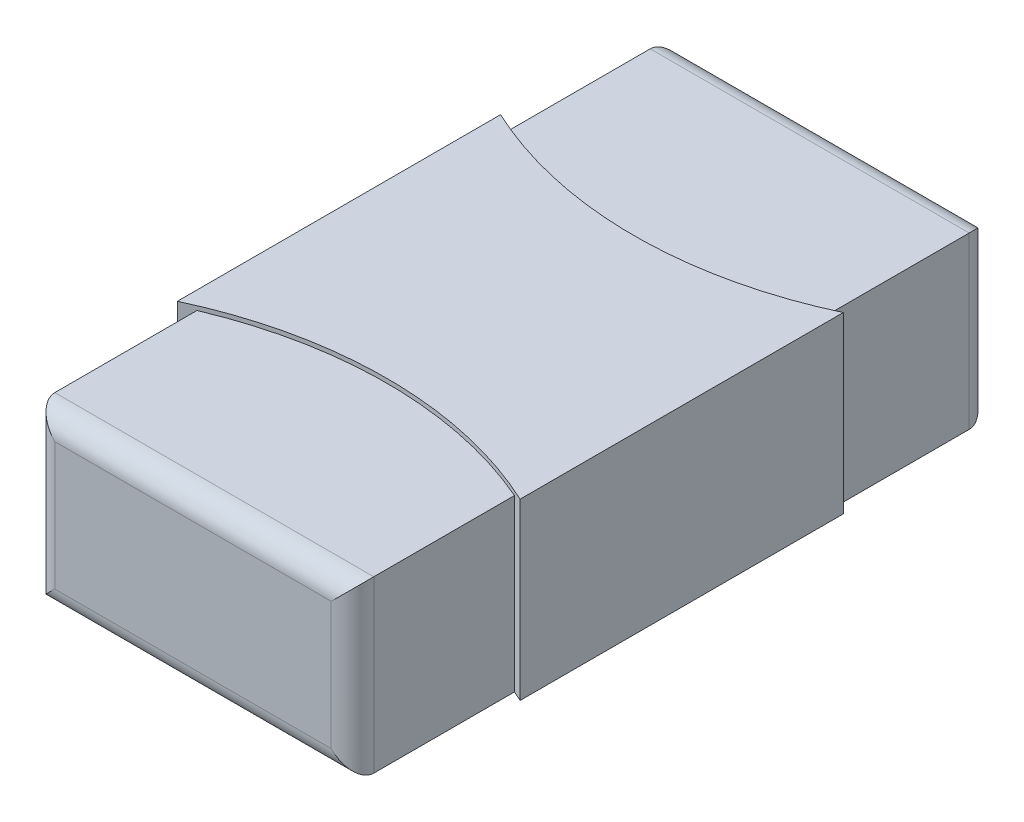
from build123d import *

# Parameters (mm, degrees)
ESQUISSE1_W             = 1.5
ESQUISSE1_H             = 3
BOSS_EXTRU_1_DEPTH      = 0.8
CONG_1_R                = 0.1
BOSS_EXTRU_2_DEPTH      = 0.02
BOSS_EXTRU_2_DEPTH_BACK = 0.8


with BuildPart() as part:
    # Esquisse1 → Boss.-Extru.1 (new body)
    with BuildSketch(Plane(origin=(0, 0, 0), x_dir=(1, 0, 0), z_dir=(0, 1, 0))):
        Rectangle(ESQUISSE1_W, ESQUISSE1_H)
    extrude(amount=BOSS_EXTRU_1_DEPTH)

    # Congé1
    cong_1_edges = [part.edges().sort_by_distance(p)[0] for p in [
        (0, 0.8, -1.5),
        (0, 0, -1.5),
        (0, 0, 1.5),
        (0, 0.8, 1.5),
        (-0.75, 0.4, -1.5),
        (0.75, 0.4, -1.5),
        (0.75, 0.4, 1.5),
        (-0.75, 0.4, 1.5),
    ]]
    fillet(cong_1_edges, radius=CONG_1_R)

    # Esquisse2 → Boss.-Extru.2 (add, two sides)
    with BuildSketch(Plane(origin=(0, 0.8, 0), x_dir=(1, 0, 0), z_dir=(0, 1, 0))) as boss_extru_2_sk:
        with BuildLine():
            Line((-0.813673936, -0.759907702), (-0.813673936, 0.759907702))
            ThreePointArc((-0.813673936, 0.759907702), (-0.007860433, 0.580975839), (0.797952705, 0.759909342))
            Line((0.797952705, 0.759909342), (0.797952705, -0.759909342))
            ThreePointArc((0.797952705, -0.759909342), (-0.007860433, -0.580975839), (-0.813673936, -0.759907702))
        make_face()
    extrude(amount=BOSS_EXTRU_2_DEPTH)
    extrude(boss_extru_2_sk.sketch, amount=-BOSS_EXTRU_2_DEPTH_BACK)


solid = part.part
